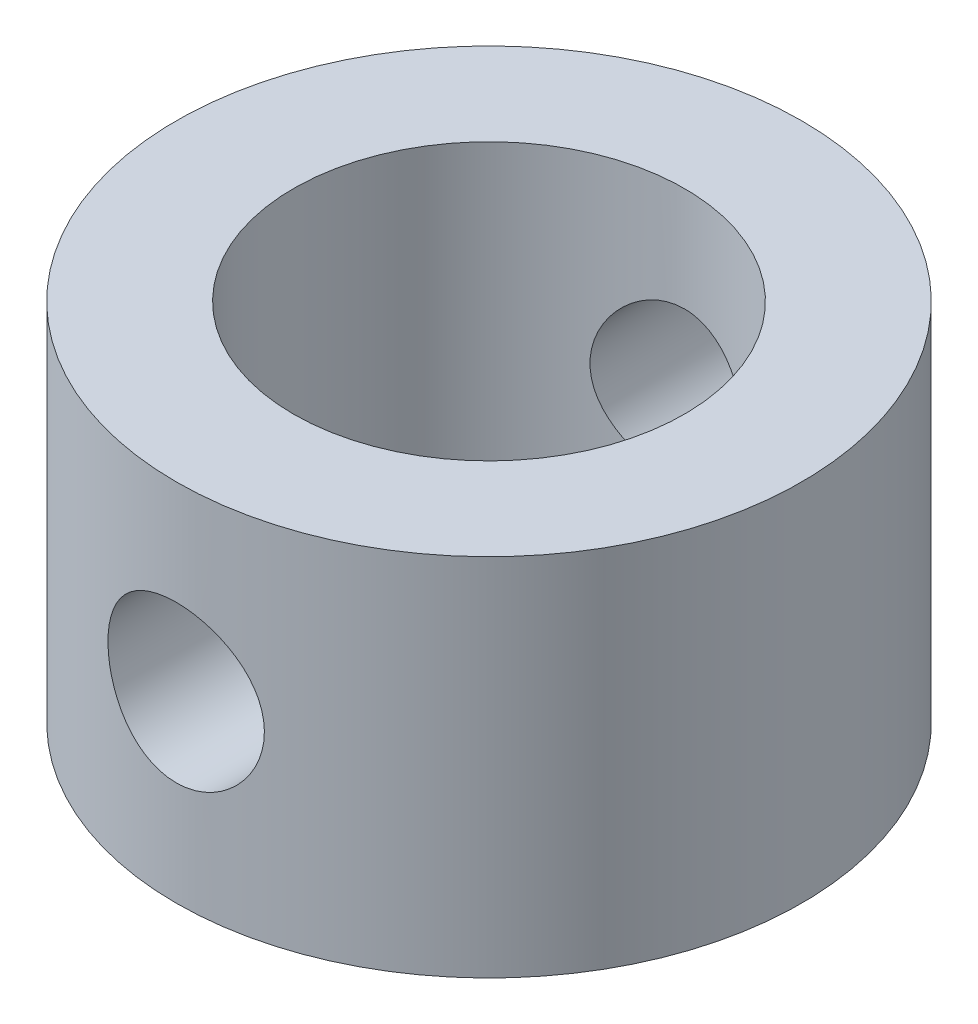
from build123d import *

# Parameters (mm, degrees)
SKETCH1_R               = 12
SKETCH1_R_2             = 7.5
BOSS_EXTRUDE1_DEPTH     = 7
SKETCH2_R               = 3
CUT_EXTRUDE1_DEPTH      = 13
CUT_EXTRUDE1_DEPTH_BACK = 13


with BuildPart() as part:
    # Sketch1 → Boss-Extrude1 (new body, symmetric)
    with BuildSketch(Plane(origin=(0, 0, 0), x_dir=(1, 0, 0), z_dir=(0, 1, 0))):
        Circle(SKETCH1_R)
        Circle(SKETCH1_R_2, mode=Mode.SUBTRACT)
    extrude(amount=BOSS_EXTRUDE1_DEPTH, both=True)

    # Sketch2 → Cut-Extrude1 (cut, two sides)
    with BuildSketch(Plane.XY) as cut_extrude1_sk:
        Circle(SKETCH2_R)
    extrude(amount=CUT_EXTRUDE1_DEPTH, mode=Mode.SUBTRACT)
    extrude(cut_extrude1_sk.sketch, amount=-CUT_EXTRUDE1_DEPTH_BACK, mode=Mode.SUBTRACT)


solid = part.part
